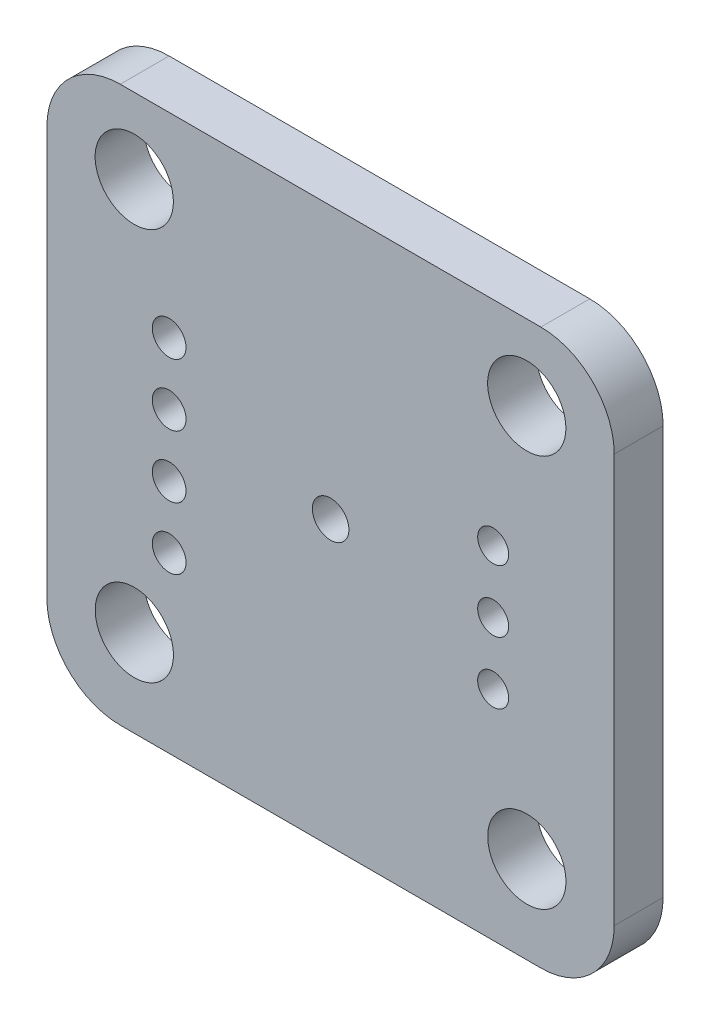
from build123d import *

# Parameters (mm, degrees)
SKETCH1_W           = 23.2
SKETCH1_H           = 22.7
SKETCH1_R           = 1.6
BOSS_EXTRUDE1_DEPTH = 2
FILLET1_R           = 3
SKETCH2_R           = 0.633596253
SKETCH2_R_2         = 0.690319611
CUT_EXTRUDE1_DEPTH  = 3
SKETCH3_R           = 0.746836088
CUT_EXTRUDE2_DEPTH  = 3


with BuildPart() as part:
    # Sketch1 → Boss-Extrude1 (new body)
    with BuildSketch(Plane.XY):
        with Locations((-0.002931945, -0.247067135)):
            Rectangle(SKETCH1_W, SKETCH1_H)
        with Locations((-8.029814258, 8.024213837)):
            Circle(SKETCH1_R, mode=Mode.SUBTRACT)
        with Locations((8.021282811, 8.026881394)):
            Circle(SKETCH1_R, mode=Mode.SUBTRACT)
        with Locations((8.023950367, -8.024215675)):
            Circle(SKETCH1_R, mode=Mode.SUBTRACT)
        with Locations((-8.027146702, -8.026883232)):
            Circle(SKETCH1_R, mode=Mode.SUBTRACT)
    extrude(amount=BOSS_EXTRUDE1_DEPTH)

    # Fillet1
    fillet1_edges = [part.edges().sort_by_distance(p)[0] for p in [
        (11.597068055, -11.597067135, 1),
        (-11.602931945, -11.597067135, 1),
        (-11.602931945, 11.102932865, 1),
        (11.597068055, 11.102932865, 1),
    ]]
    fillet(fillet1_edges, radius=FILLET1_R)

    # Sketch2 → Cut-Extrude1 (cut, through all)
    with BuildSketch(Plane.XY.offset(2)):
        with Locations((6.647068055, -2.697067135)):
            Circle(SKETCH2_R)
        with Locations((6.647068055, -0.157067135)):
            Circle(SKETCH2_R)
        with Locations((6.647068055, 2.382932865)):
            Circle(SKETCH2_R)
        with Locations((-6.602931945, -4.497067135)):
            Circle(SKETCH2_R_2)
        with Locations((-6.602931945, -1.957067135)):
            Circle(SKETCH2_R_2)
        with Locations((-6.602931945, 0.582932865)):
            Circle(SKETCH2_R_2)
        with Locations((-6.602931945, 3.122932865)):
            Circle(SKETCH2_R_2)
    extrude(amount=-CUT_EXTRUDE1_DEPTH, mode=Mode.SUBTRACT)

    # Sketch3 → Cut-Extrude2 (cut, through all)
    with BuildSketch(Plane.XY.offset(2)):
        Circle(SKETCH3_R)
    extrude(amount=-CUT_EXTRUDE2_DEPTH, mode=Mode.SUBTRACT)


solid = part.part
